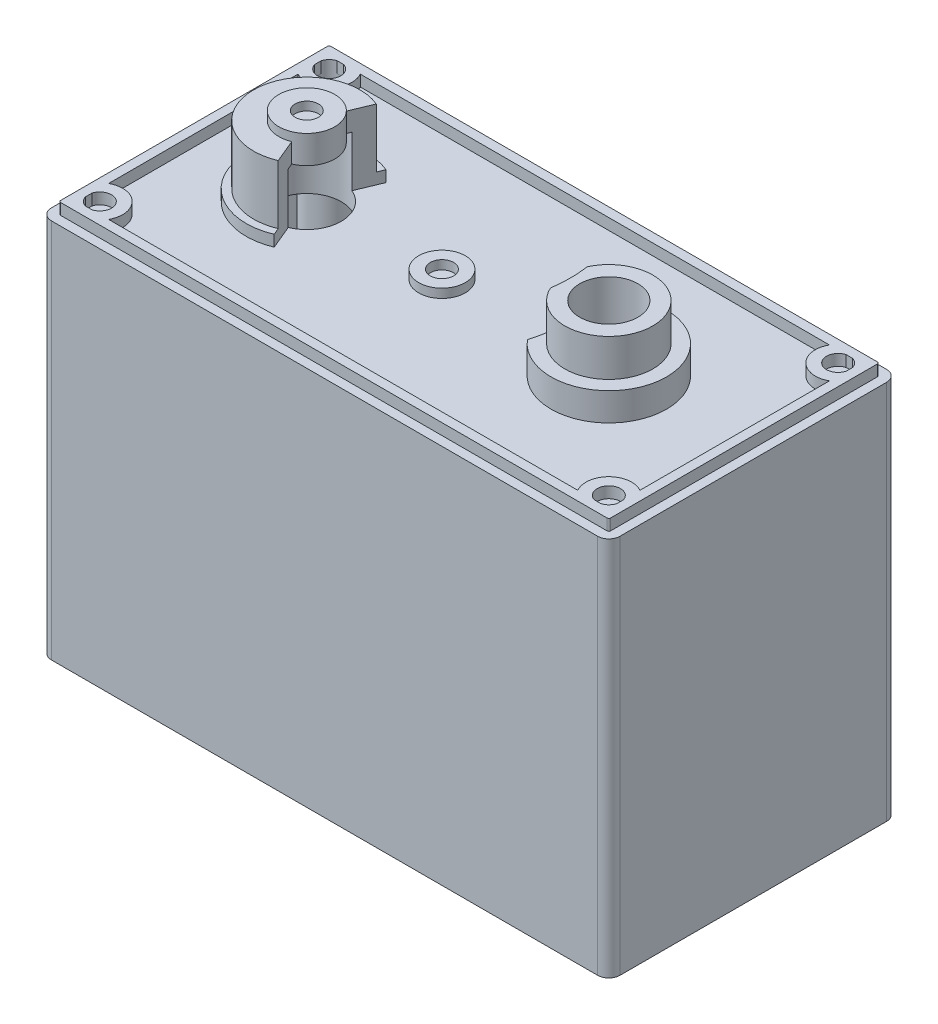
from build123d import *

# Parameters (mm, degrees)
SKETCH1_R                       = 2.3495
SKETCH1_R_2                     = 1.9812
EXTRUDE1_DEPTH                  = 1.190625
SKETCH6_R                       = 1.5875
SKETCH6_R_2                     = 0.79375
EXTRUDE3_DEPTH                  = 0.6096
SKETCH7_R                       = 3
SKETCH7_R_2                     = 1.9812
EXTRUDE4_DEPTH                  = 4.445
SKETCH16_R                      = 3.937
SKETCH16_R_2                    = 3
EXTRUDE11_DEPTH                 = 1.905
CUT_EXTRUDE1_REACH              = 24.444
SKETCH11_R                      = 7.874
SKETCH11_R_2                    = 6.604
EXTRUDE6_DEPTH                  = 4.572
SKETCH10_W                      = 37.211
SKETCH10_H                      = 18.161
EXTRUDE5_DEPTH                  = 25.90546
SKETCH13_W                      = 1.143
SKETCH13_H                      = 3.048
EXTRUDE8_DEPTH                  = 10.795
EXTRUDE9_START                  = -1.952625
SKETCH14_R                      = 0.79375
EXTRUDE9_DEPTH                  = 26.66746
SKETCH23_R                      = 0.79375
CUT_EXTRUDE2_DEPTH              = 1.190625
CUT_EXTRUDE3_REACH              = 39.594
MIRROR2_START                   = -1.952625
MIRROR2_COPY_1_SKETCH_R         = 0.79375
MIRROR2_COPY_1_DEPTH            = 26.66746
SKETCH18_W                      = 36.195
SKETCH18_H                      = 17.145
EXTRUDE12_DEPTH                 = 0.762
SKETCH19_R                      = 2.54
EXTRUDE13_DEPTH                 = 1.905
EXTRUDE14_DEPTH                 = 5.588
F_1_64_TAPPED_HOLE1_D           = 1.5113
F_1_64_TAPPED_HOLE1_DEPTH       = 5.588
F_1_64_TAPPED_HOLE1_CBORE_D     = 1.8542
F_1_64_TAPPED_HOLE1_CBORE_DEPTH = 3.7084


with BuildPart() as part:
    # Sketch1 → Extrude1 (new body)
    with BuildSketch(Plane(origin=(0, 0, 0), x_dir=(1, 0, 0), z_dir=(0, 1, 0))):
        with BuildLine():
            Line((-18.6055, 9.8425), (18.6055, 9.8425))
            ThreePointArc((18.6055, 9.8425), (19.144315367, 9.619315367), (19.3675, 9.0805))
            Line((19.3675, 9.0805), (19.3675, -9.0805))
            ThreePointArc((19.3675, -9.0805), (19.144315367, -9.619315367), (18.6055, -9.8425))
            Line((18.6055, -9.8425), (-18.6055, -9.8425))
            ThreePointArc((-18.6055, -9.8425), (-19.144315367, -9.619315367), (-19.3675, -9.0805))
            Line((-19.3675, -9.0805), (-19.3675, 9.0805))
            ThreePointArc((-19.3675, 9.0805), (-19.144315367, 9.619315367), (-18.6055, 9.8425))
        make_face()
        with Locations(Location((-11.049, 0, 0), (0, 0, 90))):
            Circle(SKETCH1_R, mode=Mode.SUBTRACT)
        with Locations(Location((9.525, 0, 0), (0, 0, 90))):
            Circle(SKETCH1_R_2, mode=Mode.SUBTRACT)
    extrude(amount=EXTRUDE1_DEPTH)

    # Sketch6 → Extrude3 (add)
    with BuildSketch(Plane(origin=(0, 1.190625, 0), x_dir=(-1, 0, 0), z_dir=(0, 1, 0))):
        with Locations(Location((1.8415, 0, 0), (0, 0, 270))):
            Circle(SKETCH6_R)
        with Locations(Location((1.8415, 0, 0), (0, 0, 90))):
            Circle(SKETCH6_R_2, mode=Mode.SUBTRACT)
    extrude(amount=EXTRUDE3_DEPTH)

    # Sketch7 → Extrude4 (add)
    with BuildSketch(Plane(origin=(0, 1.190625, 0), x_dir=(-1, 0, 0), z_dir=(0, 1, 0))):
        with Locations(Location((-9.525, 0, 0), (0, 0, 270))):
            Circle(SKETCH7_R)
        with Locations(Location((-9.525, 0, 0), (0, 0, 270))):
            Circle(SKETCH7_R_2, mode=Mode.SUBTRACT)
    extrude(amount=EXTRUDE4_DEPTH)

    # Sketch16 → Extrude11 (add)
    with BuildSketch(Plane(origin=(0, 1.190625, 0), x_dir=(-1, 0, 0), z_dir=(0, 1, 0))):
        with Locations(Location((-9.525, 0, 0), (0, 0, 270))):
            Circle(SKETCH16_R)
        with Locations(Location((-9.525, 0, 0), (0, 0, 90))):
            Circle(SKETCH16_R_2, mode=Mode.SUBTRACT)
    extrude(amount=EXTRUDE11_DEPTH)

    # Cut-Extrude1: up to this face of the body (flat: up to its plane)
    cut_extrude1_end = Plane(part.part.faces().sort_by_distance((0, 1.190625, -9.408000351))[0])
    # Sketch17 → Cut-Extrude1 (cut, up to the picked face)
    with BuildSketch(Plane(origin=(0, 5.635625, 0), x_dir=(-1, 0, 0), z_dir=(0, 1, 0)), mode=Mode.PRIVATE) as cut_extrude1_sk1:
        with BuildLine():
            ThreePointArc((-6.516949302, 2.54), (-6.894361419, 0), (-6.516949302, -2.54))
            ThreePointArc((-6.516949302, -2.54), (-5.588, 0), (-6.516949302, 2.54))
        make_face()
    cut_extrude1_tool1 = split(extrude(cut_extrude1_sk1.sketch, amount=-CUT_EXTRUDE1_REACH, mode=Mode.PRIVATE), bisect_by=cut_extrude1_end, keep=Keep.BOTH, mode=Mode.PRIVATE)
    add(cut_extrude1_tool1.solids().sort_by(Axis((6.291228, 5.635625, 0), (0, -1, 0)))[0], mode=Mode.SUBTRACT)

    # Sketch11 → Extrude6 (add)
    with BuildSketch(Plane.XZ):
        with Locations(Location((9.525, 0, 0), (0, 0, 270))):
            Circle(SKETCH11_R)
        with Locations(Location((9.525, 0, 0), (0, 0, 270))):
            Circle(SKETCH11_R_2, mode=Mode.SUBTRACT)
    extrude(amount=EXTRUDE6_DEPTH)

    # Sketch10 → Extrude5 (add)
    with BuildSketch(Plane.XZ.offset(-1.190625)):
        with BuildLine():
            Line((-19.3675, 9.0805), (-19.3675, -9.0805))
            ThreePointArc((-19.3675, -9.0805), (-19.144315367, -9.619315367), (-18.6055, -9.8425))
            Line((-18.6055, -9.8425), (18.6055, -9.8425))
            ThreePointArc((18.6055, -9.8425), (19.144315367, -9.619315367), (19.3675, -9.0805))
            Line((19.3675, -9.0805), (19.3675, 9.0805))
            ThreePointArc((19.3675, 9.0805), (19.144315367, 9.619315367), (18.6055, 9.8425))
            Line((18.6055, 9.8425), (-18.6055, 9.8425))
            ThreePointArc((-18.6055, 9.8425), (-19.144315367, 9.619315367), (-19.3675, 9.0805))
        make_face()
        Rectangle(SKETCH10_W, SKETCH10_H, mode=Mode.SUBTRACT)
    extrude(amount=EXTRUDE5_DEPTH)

    # Sketch13 → Extrude8 (add)
    with BuildSketch(Plane.XZ):
        with BuildLine():
            Line((-5.9055, 6.0325), (-5.9055, 9.0805))
            Line((-5.9055, 9.0805), (-4.7625, 9.0805))
            Line((-4.7625, 9.0805), (-4.7625, 6.713831938))
            ThreePointArc((-4.7625, 6.713831938), (-1.851412189, 0), (-4.7625, -6.713831938))
            Line((-4.7625, -6.713831938), (-4.7625, -9.0805))
            Line((-4.7625, -9.0805), (-5.9055, -9.0805))
            Line((-5.9055, -9.0805), (-5.9055, -6.0325))
            ThreePointArc((-5.9055, -6.0325), (-3.121412189, 0), (-5.9055, 6.0325))
        make_face()
        with Locations((-8.382, 7.5565)):
            Rectangle(SKETCH13_W, SKETCH13_H)
        with Locations((-13.335, 7.5565)):
            Rectangle(SKETCH13_W, SKETCH13_H)
        with Locations((-13.335, -7.5565)):
            Rectangle(SKETCH13_W, SKETCH13_H)
        with Locations((-8.382, -7.5565)):
            Rectangle(SKETCH13_W, SKETCH13_H)
    extrude(amount=EXTRUDE8_DEPTH)

    # Sketch14 → Extrude9 (add)
    with BuildSketch(Plane.XZ.offset(EXTRUDE9_START)):
        with BuildLine():
            Line((-18.6055, -9.0805), (-18.6055, -6.911913297))
            ThreePointArc((-18.6055, -6.911913297), (-16.235418625, -6.710418625), (-16.436913297, -9.0805))
            Line((-16.436913297, -9.0805), (-18.6055, -9.0805))
        make_face()
        with Locations(Location((-17.3355, -7.8105, 0), (0, 0, 270))):
            Circle(SKETCH14_R, mode=Mode.SUBTRACT)
    extrude9 = extrude(amount=EXTRUDE9_DEPTH)

    # Sketch23 → Cut-Extrude2 (cut)
    with BuildSketch(Plane(origin=(0, 1.190625, 0), x_dir=(-1, 0, 0), z_dir=(0, 1, 0))):
        with Locations(Location((17.3355, -7.8105, 0), (0, 0, 270))):
            Circle(SKETCH23_R)
    extrude(amount=-CUT_EXTRUDE2_DEPTH, mode=Mode.SUBTRACT)

    # Sketch9 → Revolve1 (revolve)
    with BuildSketch(Plane.XY, mode=Mode.PRIVATE) as revolve1_sk:
        Polygon((-12.954, 5.965825), (-12.954, 6.550025), (-11.84275, 6.550025), (-11.84275, 5.965825), (-11.049, 5.965825), (-11.049, 4.645025), (-13.3985, 4.645025), (-13.3985, 1.190625), (-15.1765, 1.190625), (-15.1765, 1.952625), (-14.6685, 1.952625), (-14.6685, 5.965825), align=None)
    revolve(revolve1_sk.sketch.rotate(Axis((-11.049, 0, 0), (0, 1, 0)), 270), axis=Axis((-11.049, 0, 0), (0, 1, 0)))

    # Cut-Extrude3: up to this face of the body (flat: up to its plane)
    cut_extrude3_end = Plane(part.part.faces().sort_by_distance((-1.8415, 1.190625, 0))[0])
    # Sketch24 → Cut-Extrude3 (cut, up to the picked face)
    with BuildSketch(Plane(origin=(0, 5.965825, 0), x_dir=(-1, 0, 0), z_dir=(0, 1, 0)), mode=Mode.PRIVATE) as cut_extrude3_sk1:
        with BuildLine():
            Line((10.316307692, 1.758461538), (9.4615, 3.81))
            ThreePointArc((9.4615, 3.81), (6.9215, 0), (9.4615, -3.81))
            Line((9.4615, -3.81), (10.316307692, -1.758461538))
            ThreePointArc((10.316307692, -1.758461538), (9.144, 0), (10.316307692, 1.758461538))
        make_face()
    cut_extrude3_tool1 = split(extrude(cut_extrude3_sk1.sketch, amount=-CUT_EXTRUDE3_REACH, mode=Mode.PRIVATE), bisect_by=cut_extrude3_end, keep=Keep.BOTH, mode=Mode.PRIVATE)
    add(cut_extrude3_tool1.solids().sort_by(Axis((-8.574349, 5.965825, 0), (0, -1, 0)))[0], mode=Mode.SUBTRACT)

    # Mirror1: Extrude9 across plane
    add(extrude9.mirror(Plane(origin=(0, 0, 0), x_dir=(0, 0, 1), z_dir=(1, 0, 0))))

    # Mirror2: Extrude9 across plane
    add(extrude9.mirror(Plane.XY))

    # Mirror2 copy 1 sketch → Mirror2 copy 1 (add)
    with BuildSketch(Plane(origin=(0, 0, 0), x_dir=(-1, 0, 0), z_dir=(0, -1, 0)).offset(MIRROR2_START)):
        with BuildLine():
            Line((-18.6055, -9.0805), (-18.6055, -6.911913297))
            ThreePointArc((-18.6055, -6.911913297), (-16.235418625, -6.710418625), (-16.436913297, -9.0805))
            Line((-16.436913297, -9.0805), (-18.6055, -9.0805))
        make_face()
        with Locations(Location((-17.3355, -7.8105, 0), (0, 0, 270))):
            Circle(MIRROR2_COPY_1_SKETCH_R, mode=Mode.SUBTRACT)
    extrude(amount=MIRROR2_COPY_1_DEPTH)

    # Sketch18 → Extrude12 (add)
    with BuildSketch(Plane(origin=(0, 1.952625, 0), x_dir=(-1, 0, 0), z_dir=(0, 1, 0))):
        with BuildLine():
            Line((18.6055, 9.2075), (-18.6055, 9.2075))
            ThreePointArc((-18.6055, 9.2075), (-18.695302561, 9.170302561), (-18.7325, 9.0805))
            Line((-18.7325, 9.0805), (-18.7325, -9.0805))
            ThreePointArc((-18.7325, -9.0805), (-18.695302561, -9.170302561), (-18.6055, -9.2075))
            Line((-18.6055, -9.2075), (18.6055, -9.2075))
            ThreePointArc((18.6055, -9.2075), (18.695302561, -9.170302561), (18.7325, -9.0805))
            Line((18.7325, -9.0805), (18.7325, 9.0805))
            ThreePointArc((18.7325, 9.0805), (18.695302561, 9.170302561), (18.6055, 9.2075))
        make_face()
        Rectangle(SKETCH18_W, SKETCH18_H, mode=Mode.SUBTRACT)
    extrude(amount=-EXTRUDE12_DEPTH)

    # Sketch19 → Extrude13 (add)
    with BuildSketch(Plane.XZ):
        with BuildLine():
            Line((11.557, -3.222898695), (11.557, -6.283612973))
            ThreePointArc((11.557, -6.283612973), (11.178939296, -6.393535861), (10.795, -6.480734218))
            Line((10.795, -6.480734218), (10.795, -3.592102448))
            ThreePointArc((10.795, -3.592102448), (9.525, -3.81), (8.255, -3.592102448))
            Line((8.255, -3.592102448), (8.255, -6.480734218))
            ThreePointArc((8.255, -6.480734218), (7.871060704, -6.393535861), (7.493, -6.283612973))
            Line((7.493, -6.283612973), (7.493, -3.222898695))
            ThreePointArc((7.493, -3.222898695), (9.525, 3.81), (11.557, -3.222898695))
        make_face()
        with Locations(Location((9.525, 0, 0), (0, 0, 90))):
            Circle(SKETCH19_R, mode=Mode.SUBTRACT)
    extrude(amount=EXTRUDE13_DEPTH)

    # Sketch20 → Extrude14 (add)
    with BuildSketch(Plane.XZ):
        with BuildLine():
            ThreePointArc((4.320531036, -4.065257532), (3.147336001, -7.413112903), (6.282470752, -5.753157401))
            ThreePointArc((6.282470752, -5.753157401), (5.218006131, -5.006258065), (4.320531036, -4.065257532))
        make_face()
    extrude(amount=EXTRUDE14_DEPTH)

    # 1-64 Tapped Hole1
    with Locations(Plane(origin=(4.389738079, -5.588, -5.969), x_dir=(0, 0, -1), z_dir=(0, -1, 0))):
        with Locations((0, 0)):
            CounterBoreHole(F_1_64_TAPPED_HOLE1_D / 2, F_1_64_TAPPED_HOLE1_CBORE_D / 2, F_1_64_TAPPED_HOLE1_CBORE_DEPTH, depth=F_1_64_TAPPED_HOLE1_DEPTH)


solid = part.part
